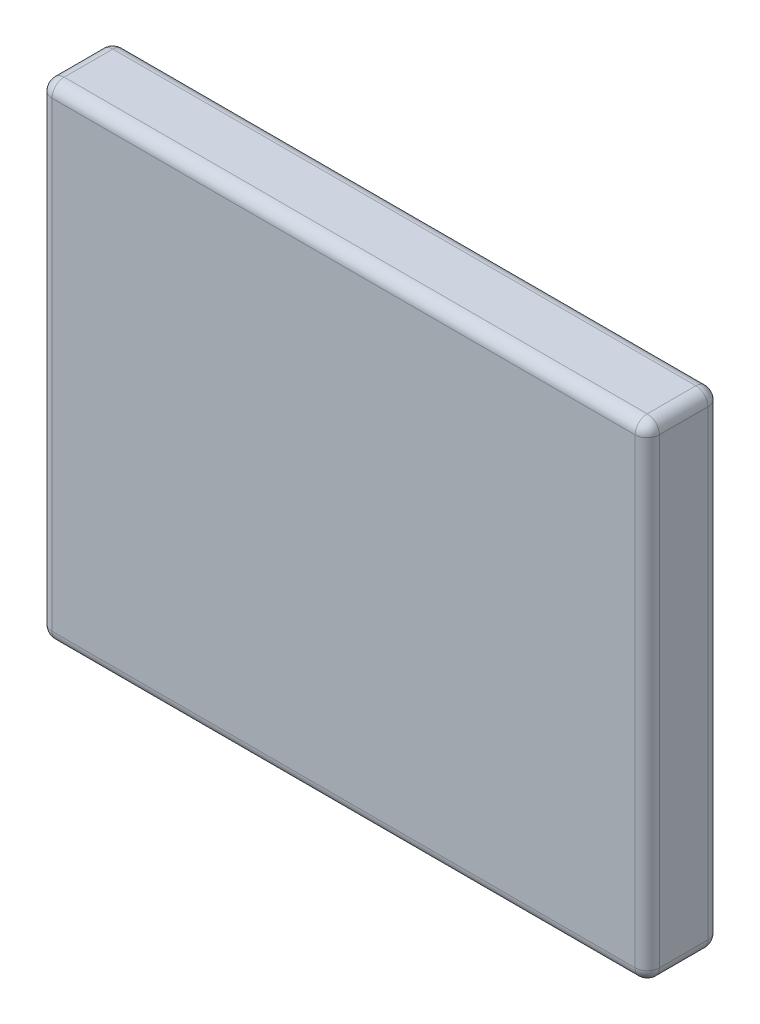
from build123d import *

# Parameters (mm, degrees)
SCHIZZO1_W                   = 25
SCHIZZO1_H                   = 20
ESTRUSIONE_ESTRUSIONE1_DEPTH = 3
RACCORDO1_R                  = 0.5


with BuildPart() as part:
    # Schizzo1 → Estrusione-Estrusione1 (new body)
    with BuildSketch(Plane.XY):
        Rectangle(SCHIZZO1_W, SCHIZZO1_H)
    extrude(amount=ESTRUSIONE_ESTRUSIONE1_DEPTH)

    # Raccordo1
    raccordo1_edges = [part.edges().sort_by_distance(p)[0] for p in [
        (0, -10, 3),
        (-12.5, 0, 3),
        (0, 10, 3),
        (-12.5, 0, 0),
        (0, -10, 0),
        (12.5, 0, 0),
        (0, 10, 0),
        (-12.5, 10, 1.5),
        (-12.5, -10, 1.5),
        (12.5, -10, 1.5),
        (12.5, 10, 1.5),
        (12.5, 0, 3),
    ]]
    fillet(raccordo1_edges, radius=RACCORDO1_R)


solid = part.part
